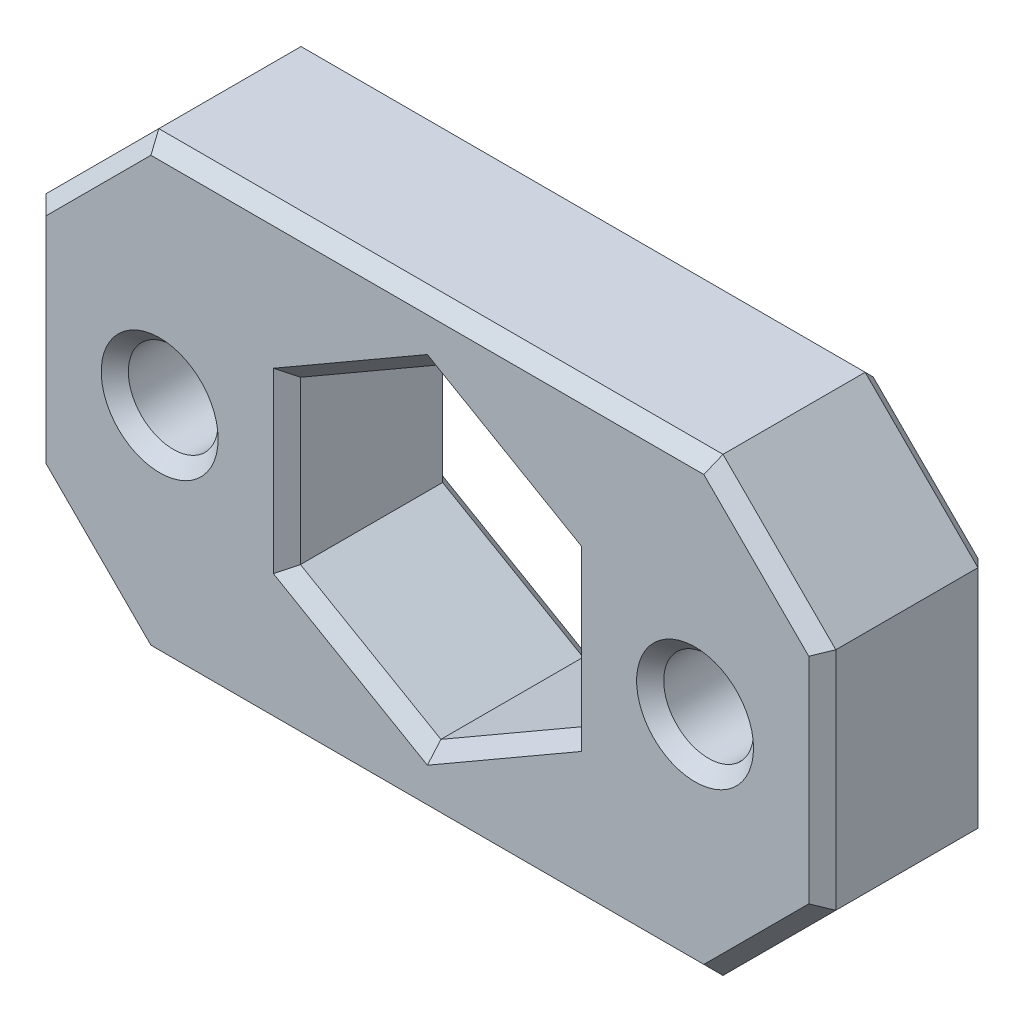
from build123d import *

# Parameters (mm, degrees)
SKETCH1_W                  = 44.45
SKETCH1_H                  = 25.4
BOSS_EXTRUDE1_DEPTH        = 9.525
CHAMFER1_SIZE              = 6.35
HOLE1_AT_2_COUNT           = 2
HOLE1_AT_2_PITCH           = 30.13075
F_8_0_199_DIAMETER_HOLE1_D = 5.0546
CHAMFER2_SIZE              = 0.762


with BuildPart() as part:
    # Sketch1 → Boss-Extrude1 (new body)
    with BuildSketch(Plane.XY):
        with Locations((35.268404938, -193.371995598)):
            Rectangle(SKETCH1_W, SKETCH1_H)
        Polygon((43.174154938, -197.936382488), (43.174154938, -188.807608707), (35.268404938, -184.243221816), (27.362654938, -188.807608707), (27.362654938, -197.936382488), (35.268404938, -202.500769379), align=None, mode=Mode.SUBTRACT)
    extrude(amount=BOSS_EXTRUDE1_DEPTH)

    # Chamfer1
    chamfer1_edges = [part.edges().sort_by_distance(p)[0] for p in [
        (13.043404938, -180.671995598, 4.7625),
        (57.493404938, -180.671995598, 4.7625),
        (57.493404938, -206.071995598, 4.7625),
        (13.043404938, -206.071995598, 4.7625),
    ]]
    chamfer(chamfer1_edges, length=CHAMFER1_SIZE)

    # Sketch3 → Hole1 (revolve, cut)
    with BuildSketch(Plane(origin=(20.203029938, -193.371995598, 0), x_dir=(0, 1, 0), z_dir=(1, 0, 0))):
        Polygon((0, 0), (0, 4.699), (2.8702, 4.699), (2.9972, 0), align=None)
    hole1 = revolve(axis=Axis((20.203029938, -193.371995598, 110), (0, 0, -1)), mode=Mode.SUBTRACT)

    # Hole1 at 2: Hole1 ×2
    with Locations(*[(i * HOLE1_AT_2_PITCH, 0, 0) for i in range(1, HOLE1_AT_2_COUNT)]):
        add(hole1, mode=Mode.SUBTRACT)

    # #8 (0.199) Diameter Hole1 (through all)
    with Locations(Plane(origin=(0, 0, 0), x_dir=(-1, 0, 0), z_dir=(0, 0, -1))):
        with Locations((-50.333779938, -193.371995598), (-20.203029938, -193.371995598)):
            Hole(F_8_0_199_DIAMETER_HOLE1_D / 2)

    # Chamfer2
    chamfer2_edges = [part.edges().sort_by_distance(p)[0] for p in [
        (39.221279938, -200.218575934, 0),
        (43.174154938, -193.371995598, 0),
        (39.221279938, -186.525415262, 0),
        (31.315529938, -186.525415262, 0),
        (27.362654938, -193.371995598, 0),
        (31.315529938, -200.218575934, 0),
        (39.221279938, -200.218575934, 9.525),
        (43.174154938, -193.371995598, 9.525),
        (39.221279938, -186.525415262, 9.525),
        (31.315529938, -186.525415262, 9.525),
        (27.362654938, -193.371995598, 9.525),
        (31.315529938, -200.218575934, 9.525),
        (35.268404938, -180.671995598, 0),
        (35.268404938, -180.671995598, 9.525),
        (13.043404938, -193.371995598, 0),
        (57.493404938, -193.371995598, 0),
        (35.268404938, -206.071995598, 0),
        (16.218404938, -183.846995598, 0),
        (16.218404938, -202.896995598, 0),
        (54.318404938, -202.896995598, 0),
        (54.318404938, -183.846995598, 0),
        (57.493404938, -193.371995598, 9.525),
        (13.043404938, -193.371995598, 9.525),
        (35.268404938, -206.071995598, 9.525),
        (16.218404938, -183.846995598, 9.525),
        (16.218404938, -202.896995598, 9.525),
        (54.318404938, -202.896995598, 9.525),
        (54.318404938, -183.846995598, 9.525),
        (17.675729938, -193.371995598, 9.525),
        (47.806479938, -193.371995598, 9.525),
    ]]
    chamfer(chamfer2_edges, length=CHAMFER2_SIZE)


solid = part.part
